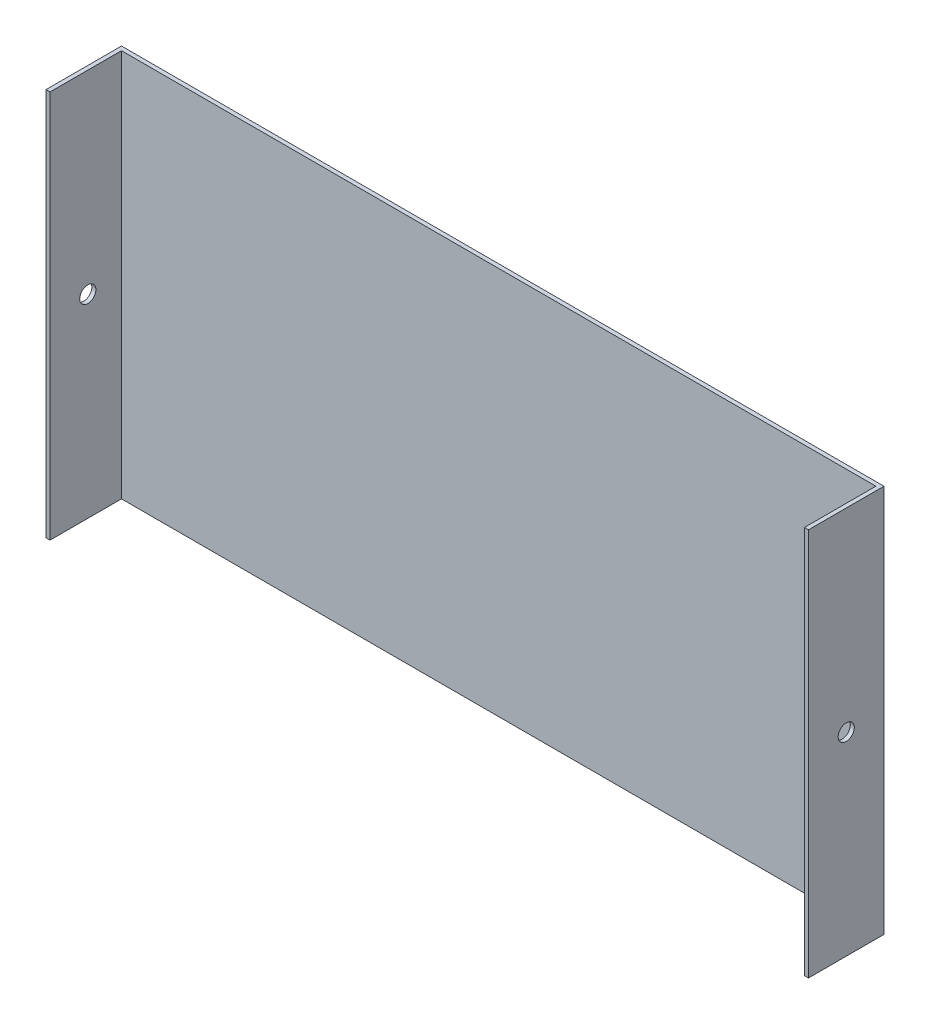
from build123d import *

# Parameters (mm, degrees)
BOSS_EXTRUDE1_DEPTH = 304.8
SKETCH2_R           = 6.35
CUT_EXTRUDE1_DEPTH  = 599.68125614


with BuildPart() as part:
    # Sketch1 → Boss-Extrude1 (new body)
    with BuildSketch(Plane(origin=(0, 0, 0), x_dir=(1, 0, 0), z_dir=(0, 1, 0))):
        Polygon((3.175, 2.097530582), (595.50625614, 2.097530582), (595.50625614, -53.975), (598.68125614, -53.975), (598.68125614, 0), (598.68125614, 5.272530582), (0, 5.272530582), (0, 0), (0, -53.975), (3.175, -53.975), align=None)
    extrude(amount=BOSS_EXTRUDE1_DEPTH)

    # Sketch2 → Cut-Extrude1 (cut, through all)
    with BuildSketch(Plane.ZY):
        with Locations((24.351234709, 152.4)):
            Circle(SKETCH2_R)
    extrude(amount=-CUT_EXTRUDE1_DEPTH, mode=Mode.SUBTRACT)


solid = part.part
